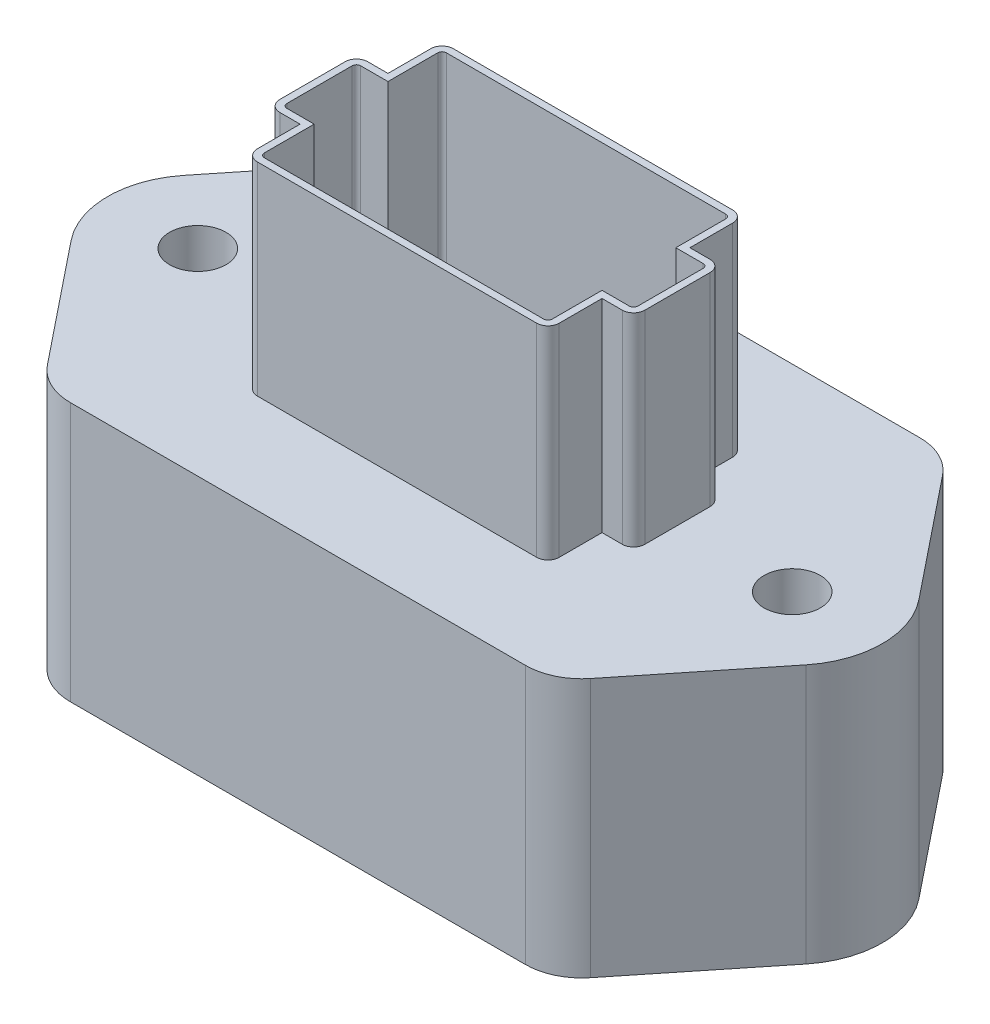
from build123d import *

# Parameters (mm, degrees)
SKETCH1_R           = 3.175
BOSS_EXTRUDE1_DEPTH = 29.21
BOSS_EXTRUDE2_DEPTH = 22.86
CUT_EXTRUDE1_REACH  = 54.07


with BuildPart() as part:
    # Sketch1 → Boss-Extrude1 (new body)
    with BuildSketch(Plane(origin=(0, 0, 0), x_dir=(1, 0, 0), z_dir=(0, 1, 0))):
        with BuildLine():
            Line((30.607538026, 19.8480292), (41.428260842, 6.35684672))
            ThreePointArc((41.428260842, 6.35684672), (43.6626, 0), (41.428260842, -6.35684672))
            Line((41.428260842, -6.35684672), (30.607538026, -19.8480292))
            ThreePointArc((30.607538026, -19.8480292), (28.401158949, -21.599999363), (25.654, -22.225))
            Line((25.654, -22.225), (-25.654, -22.225))
            ThreePointArc((-25.654, -22.225), (-28.401158949, -21.599999363), (-30.607538026, -19.8480292))
            Line((-30.607538026, -19.8480292), (-41.428260842, -6.35684672))
            ThreePointArc((-41.428260842, -6.35684672), (-43.6626, 0), (-41.428260842, 6.35684672))
            Line((-41.428260842, 6.35684672), (-30.607538026, 19.8480292))
            ThreePointArc((-30.607538026, 19.8480292), (-28.401158949, 21.599999363), (-25.654, 22.225))
            Line((-25.654, 22.225), (25.654, 22.225))
            ThreePointArc((25.654, 22.225), (28.401158949, 21.599999363), (30.607538026, 19.8480292))
        make_face()
        with Locations((-33.5026, 0)):
            Circle(SKETCH1_R, mode=Mode.SUBTRACT)
        with Locations((33.5026, 0)):
            Circle(SKETCH1_R, mode=Mode.SUBTRACT)
    extrude(amount=BOSS_EXTRUDE1_DEPTH)

    # Sketch2 → Boss-Extrude2 (add)
    with BuildSketch(Plane(origin=(0, 29.21, 0), x_dir=(1, 0, 0), z_dir=(0, 1, 0))):
        with BuildLine():
            Line((-19.304, -4.953), (-17.018, -4.953))
            Line((-17.018, -4.953), (-17.018, 4.953))
            Line((-17.018, 4.953), (-19.304, 4.953))
            ThreePointArc((-19.304, 4.953), (-20.202025612, 4.581025612), (-20.574, 3.683))
            Line((-20.574, 3.683), (-20.574, -3.683))
            ThreePointArc((-20.574, -3.683), (-20.202025612, -4.581025612), (-19.304, -4.953))
        make_face()
        with BuildLine():
            ThreePointArc((-17.018, 9.779), (-16.646025612, 10.677025612), (-15.748, 11.049))
            Line((-15.748, 11.049), (15.748, 11.049))
            ThreePointArc((15.748, 11.049), (16.646025612, 10.677025612), (17.018, 9.779))
            Line((17.018, 9.779), (17.018, -9.779))
            ThreePointArc((17.018, -9.779), (16.646025612, -10.677025612), (15.748, -11.049))
            Line((15.748, -11.049), (-15.748, -11.049))
            ThreePointArc((-15.748, -11.049), (-16.646025612, -10.677025612), (-17.018, -9.779))
            Line((-17.018, -9.779), (-17.018, 9.779))
        make_face()
        with BuildLine():
            Line((17.018, 4.953), (17.018, -4.953))
            Line((17.018, -4.953), (19.304, -4.953))
            ThreePointArc((19.304, -4.953), (20.202025612, -4.581025612), (20.574, -3.683))
            Line((20.574, -3.683), (20.574, 3.683))
            ThreePointArc((20.574, 3.683), (20.202025612, 4.581025612), (19.304, 4.953))
            Line((19.304, 4.953), (17.018, 4.953))
        make_face()
    extrude(amount=BOSS_EXTRUDE2_DEPTH)

    # Sketch4 → Cut-Extrude1 (cut, up to next)
    with BuildSketch(Plane(origin=(0, 52.07, 0), x_dir=(1, 0, 0), z_dir=(0, 1, 0)), mode=Mode.PRIVATE) as cut_extrude1_sk1:
        with BuildLine():
            Line((-16.22425, 4.15925), (-16.22425, 9.779))
            ThreePointArc((-16.22425, 9.779), (-16.084759605, 10.115759605), (-15.748, 10.25525))
            Line((-15.748, 10.25525), (15.748, 10.25525))
            ThreePointArc((15.748, 10.25525), (16.084759605, 10.115759605), (16.22425, 9.779))
            Line((16.22425, 9.779), (16.22425, 4.15925))
            Line((16.22425, 4.15925), (19.304, 4.15925))
            ThreePointArc((19.304, 4.15925), (19.640759605, 4.019759605), (19.78025, 3.683))
            Line((19.78025, 3.683), (19.78025, -3.683))
            ThreePointArc((19.78025, -3.683), (19.640759605, -4.019759605), (19.304, -4.15925))
            Line((19.304, -4.15925), (16.22425, -4.15925))
            Line((16.22425, -4.15925), (16.22425, -9.779))
            ThreePointArc((16.22425, -9.779), (16.084759605, -10.115759605), (15.748, -10.25525))
            Line((15.748, -10.25525), (-15.748, -10.25525))
            ThreePointArc((-15.748, -10.25525), (-16.084759605, -10.115759605), (-16.22425, -9.779))
            Line((-16.22425, -9.779), (-16.22425, -4.15925))
            Line((-16.22425, -4.15925), (-19.304, -4.15925))
            ThreePointArc((-19.304, -4.15925), (-19.640759605, -4.019759605), (-19.78025, -3.683))
            Line((-19.78025, -3.683), (-19.78025, 3.683))
            ThreePointArc((-19.78025, 3.683), (-19.640759605, 4.019759605), (-19.304, 4.15925))
            Line((-19.304, 4.15925), (-16.22425, 4.15925))
        make_face()
    cut_extrude1_tool1 = extrude(cut_extrude1_sk1.sketch, amount=-CUT_EXTRUDE1_REACH, mode=Mode.PRIVATE) & part.part
    add(cut_extrude1_tool1.solids().sort_by_distance((0, 52.07, 0))[0], mode=Mode.SUBTRACT)


solid = part.part
